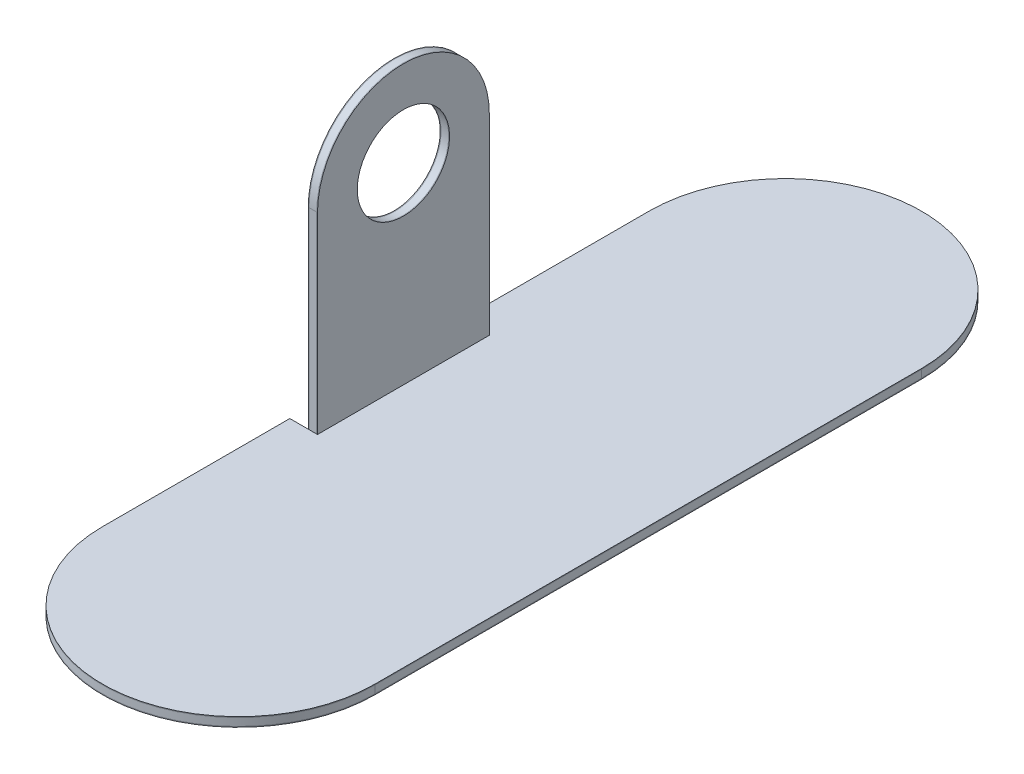
from build123d import *

# Parameters (mm, degrees)
BOSS_EXTRUDE1_DEPTH = 0.25
BOSS_EXTRUDE2_DEPTH = 2.5
BOSS_EXTRUDE3_DEPTH = 0.25
SKETCH6_R           = 15
BOSS_EXTRUDE5_DEPTH = 0.25
SKETCH7_R           = 15
BOSS_EXTRUDE7_DEPTH = 2.5
SKETCH8_R           = 15
BOSS_EXTRUDE8_DEPTH = 0.25


with BuildPart() as part:
    # Sketch1 → Boss-Extrude1 (new body)
    with BuildSketch(Plane(origin=(0, 0, 0), x_dir=(1, 0, 0), z_dir=(0, 1, 0))):
        with BuildLine():
            Line((-44.323, 88.9), (-44.323, 27.94))
            Line((-44.323, 27.94), (-35.323, 27.94))
            Line((-35.323, 27.94), (-35.323, -27.94))
            Line((-35.323, -27.94), (-44.323, -27.94))
            Line((-44.323, -27.94), (-44.323, -88.9))
            ThreePointArc((-44.323, -88.9), (0, -133.223), (44.323, -88.9))
            Line((44.323, -88.9), (44.323, 88.9))
            ThreePointArc((44.323, 88.9), (0, 133.223), (-44.323, 88.9))
        make_face()
    extrude(amount=BOSS_EXTRUDE1_DEPTH)


with BuildPart() as body_2:
    # Sketch2 → Boss-Extrude2 (new body)
    with BuildSketch(Plane(origin=(0, 0.25, 0), x_dir=(1, 0, 0), z_dir=(0, 1, 0))):
        with BuildLine():
            Line((-44.323, 27.94), (-35.323, 27.94))
            Line((-35.323, 27.94), (-35.323, -27.94))
            Line((-35.323, -27.94), (-44.323, -27.94))
            Line((-44.323, -27.94), (-44.323, -88.9))
            ThreePointArc((-44.323, -88.9), (0, -133.223), (44.323, -88.9))
            Line((44.323, -88.9), (44.323, 88.9))
            ThreePointArc((44.323, 88.9), (0, 133.223), (-44.323, 88.9))
            Line((-44.323, 88.9), (-44.323, 27.94))
        make_face()
    extrude(amount=BOSS_EXTRUDE2_DEPTH)


with BuildPart() as body_3:
    # Sketch3 → Boss-Extrude3 (new body)
    with BuildSketch(Plane(origin=(0, 2.75, 0), x_dir=(1, 0, 0), z_dir=(0, 1, 0))):
        with BuildLine():
            Line((-35.323, -27.94), (-44.323, -27.94))
            Line((-44.323, -27.94), (-44.323, -88.9))
            ThreePointArc((-44.323, -88.9), (0, -133.223), (44.323, -88.9))
            Line((44.323, -88.9), (44.323, 88.9))
            ThreePointArc((44.323, 88.9), (0, 133.223), (-44.323, 88.9))
            Line((-44.323, 88.9), (-44.323, 27.94))
            Line((-44.323, 27.94), (-35.323, 27.94))
            Line((-35.323, 27.94), (-35.323, -27.94))
        make_face()
    extrude(amount=BOSS_EXTRUDE3_DEPTH)


with BuildPart() as body_4:
    # Sketch6 → Boss-Extrude5 (new body)
    with BuildSketch(Plane.ZY.offset(35.323)):
        with BuildLine():
            ThreePointArc((27.94, 65.532), (0, 93.472), (-27.94, 65.532))
            Line((-27.94, 65.532), (-27.94, 0.25))
            Line((-27.94, 0.25), (27.94, 0))
            Line((27.94, 0), (27.94, 65.532))
        make_face()
        with Locations((0, 65.532)):
            Circle(SKETCH6_R, mode=Mode.SUBTRACT)
    extrude(amount=BOSS_EXTRUDE5_DEPTH)


with BuildPart() as body_5:
    # Sketch7 → Boss-Extrude7 (new body)
    with BuildSketch(Plane.ZY.offset(35.573)):
        with BuildLine():
            Line((-27.94, 0.25), (27.94, 0))
            Line((27.94, 0), (27.94, 65.532))
            ThreePointArc((27.94, 65.532), (0, 93.472), (-27.94, 65.532))
            Line((-27.94, 65.532), (-27.94, 0.25))
        make_face()
        with Locations((0, 65.532)):
            Circle(SKETCH7_R, mode=Mode.SUBTRACT)
    extrude(amount=BOSS_EXTRUDE7_DEPTH)


with BuildPart() as body_6:
    # Sketch8 → Boss-Extrude8 (new body)
    with BuildSketch(Plane.ZY.offset(38.073)):
        with BuildLine():
            Line((-27.94, 65.532), (-27.94, 0.25))
            Line((-27.94, 0.25), (27.94, 0))
            Line((27.94, 0), (27.94, 65.532))
            ThreePointArc((27.94, 65.532), (0, 93.472), (-27.94, 65.532))
        make_face()
        with Locations((0, 65.532)):
            Circle(SKETCH8_R, mode=Mode.SUBTRACT)
    extrude(amount=BOSS_EXTRUDE8_DEPTH)


solid = Compound([part.part, body_2.part, body_3.part, body_4.part, body_5.part, body_6.part])
